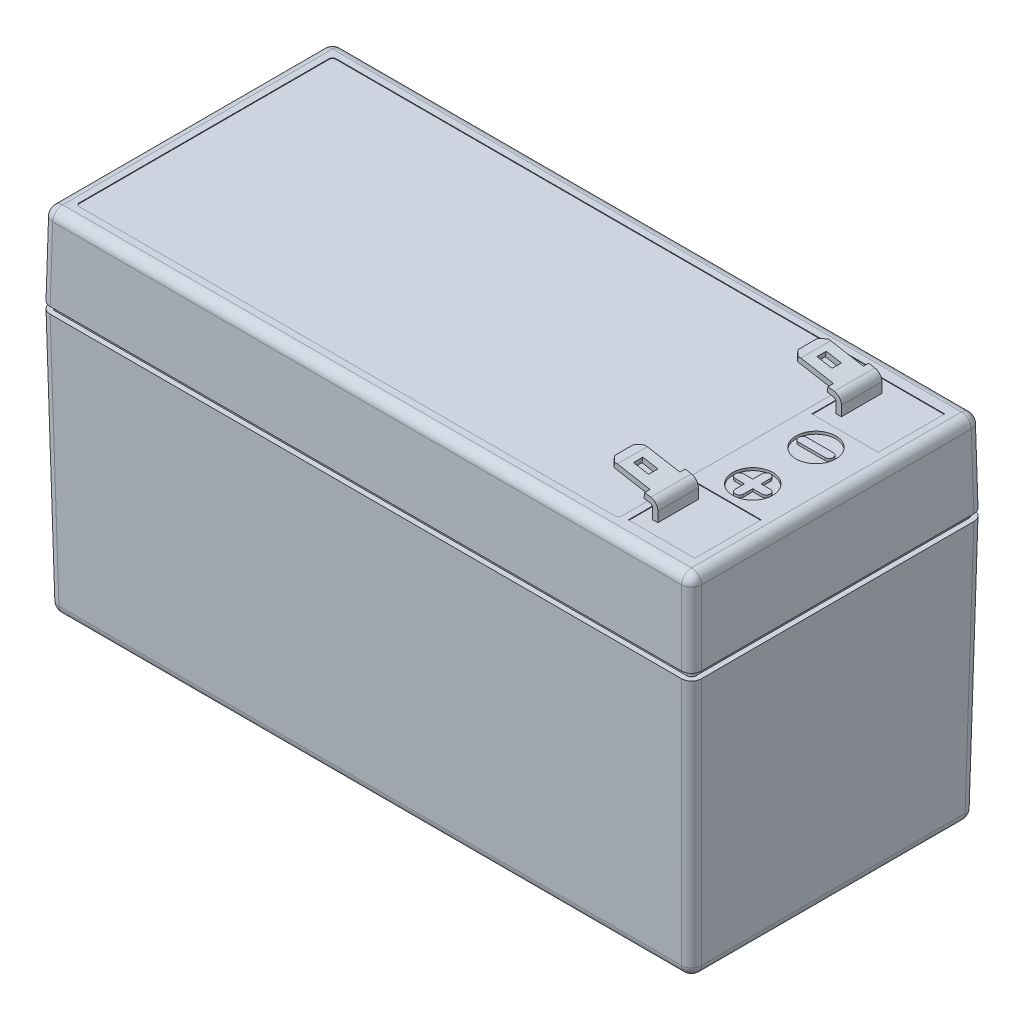
from build123d import *

# Parameters (mm, degrees)
SKETCH1_W                = 98
SKETCH1_H                = 44
EXTRUDE1_DEPTH           = 13
EXTRUDE1_TAPER           = 1
EXTRUDE1_OTHER_WAY_DEPTH = 40
EXTRUDE1_OTHER_WAY_TAPER = 1
FILLET1_R                = 1.5
SKETCH3_W                = 1.297153583
SKETCH3_H                = 1
EXTRUDE3_DEPTH           = 0.3
SKETCH4_3_W              = 3.5
SKETCH4_3_H              = 3.5
CUT_EXTRUDE1_DEPTH       = 0.5
SKETCH5_W                = 81.598076522
SKETCH5_H                = 38.598076522
CUT_EXTRUDE2_DEPTH       = 0.1
FILLET2_R                = 0.5
SKETCH6_W                = 10
SKETCH6_H                = 10
CUT_EXTRUDE3_DEPTH       = 0.1
EXTRUDE_THIN1_START      = 10.75
EXTRUDE_THIN1_DEPTH      = 6.1
SKETCH8_W                = 6.18946588
SKETCH8_H                = 0.8
SKETCH8_W_2              = 6.172101062
SKETCH8_W_3              = 2.3
SKETCH8_H_2              = 1.4
CUT_EXTRUDE4_DEPTH       = 0.8
FILLET3_R                = 0.5
FILLET4_R                = 1.3
CHAMFER1_SIZE            = 1.2
CHAMFER1_SIZE2           = 0.104986396
CHAMFER1_PART_2_SIZE     = 1.2
CHAMFER1_PART_2_SIZE2    = 0.104986396
CHAMFER1_PART_3_SIZE     = 1.2
CHAMFER1_PART_3_SIZE2    = 0.104986396
CHAMFER1_PART_4_SIZE     = 1.2
CHAMFER1_PART_4_SIZE2    = 0.104986396
CHAMFER2_SIZE            = 0.8
SKETCH9_R                = 3
CUT_EXTRUDE5_DEPTH       = 0.4


with BuildPart() as part:
    # Sketch1 → Extrude1 (new body)
    with BuildSketch(Plane(origin=(0, 0, 0), x_dir=(1, 0, 0), z_dir=(0, 1, 0))):
        Rectangle(SKETCH1_W, SKETCH1_H)
    extrude(amount=EXTRUDE1_DEPTH, taper=EXTRUDE1_TAPER)

    # Sketch1 → Extrude1 other way (add)
    with BuildSketch(Plane(origin=(0, 0, 0), x_dir=(1, 0, 0), z_dir=(0, 1, 0))):
        Rectangle(SKETCH1_W, SKETCH1_H)
    extrude(amount=-EXTRUDE1_OTHER_WAY_DEPTH, taper=EXTRUDE1_OTHER_WAY_TAPER)

    # Fillet1
    fillet1_edges = [part.edges().sort_by_distance(p)[0] for p in [
        (48.773084156, 13, 0),
        (-48.301797403, -40, 0),
        (-48.650898701, -20, 21.650898701),
        (0, -40, -21.301797403),
        (0, 13, -21.773084156),
        (-48.650898701, -20, -21.650898701),
        (48.301797403, -40, 0),
        (48.650898701, -20, -21.650898701),
        (0, -40, 21.301797403),
        (48.650898701, -20, 21.650898701),
        (-48.773084156, 13, 0),
        (0, 13, 21.773084156),
        (-48.886542078, 6.5, -21.886542078),
        (48.886542078, 6.5, -21.886542078),
        (48.886542078, 6.5, 21.886542078),
        (-48.886542078, 6.5, 21.886542078),
    ]]
    fillet(fillet1_edges, radius=FILLET1_R)

    # Cut-Sweep1: sweep along a curve in space
    with BuildLine() as cut_sweep1_path:
        Line((-49, 0, -20.500228457), (-49, 0, 20.500228457))
        add(Edge.make_bspline(
            [(-49, 0, 20.500228457), (-49, 0, 21.378829698), (-48.378829698, 0, 22), (-47.500228457, 0, 22)],
            knots=[0, 0, 0, 0, 1, 1, 1, 1], degree=3, weights=[1, 0.80480964, 0.80480964, 1]))
        Line((-47.500228457, 0, 22), (47.500228457, 0, 22))
        add(Edge.make_bspline(
            [(47.500228457, 0, 22), (48.378829698, 0, 22), (49, 0, 21.378829698), (49, 0, 20.500228457)],
            knots=[0, 0, 0, 0, 1, 1, 1, 1], degree=3, weights=[1, 0.80480964, 0.80480964, 1]))
        Line((49, 0, 20.500228457), (49, 0, -20.500228457))
        add(Edge.make_bspline(
            [(49, 0, -20.500228457), (49, 0, -21.378829698), (48.378829698, 0, -22), (47.500228457, 0, -22)],
            knots=[0, 0, 0, 0, 1, 1, 1, 1], degree=3, weights=[1, 0.80480964, 0.80480964, 1]))
        Line((47.500228457, 0, -22), (-47.500228457, 0, -22))
        add(Edge.make_bspline(
            [(-47.500228457, 0, -22), (-48.378829698, 0, -22), (-49, 0, -21.378829698), (-49, 0, -20.500228457)],
            knots=[0, 0, 0, 0, 1, 1, 1, 1], degree=3, weights=[1, 0.80480964, 0.80480964, 1]))
    # Sketch3 → Cut-Sweep1 (sweep, cut)
    with BuildSketch(Plane(origin=(0, 0, 0), x_dir=(0, 0, -1), z_dir=(1, 0, 0))):
        with Locations((21.848576792, 0)):
            Rectangle(SKETCH3_W, SKETCH3_H)
    sweep(path=cut_sweep1_path.line, mode=Mode.SUBTRACT)

    # Sketch4 → Extrude3 (add)
    with BuildSketch(Plane.XZ.offset(40)):
        Polygon((-44.627751508, -17.627751508), (-38.627751508, -17.627751508), (-38.627751508, -15.627751508), (-42.627751508, -15.627751508), (-42.627751508, -11.627751508), (-44.627751508, -11.627751508), align=None)
        Polygon((-44.627751508, 11.627751508), (-42.627751508, 11.627751508), (-42.627751508, 15.627751508), (-38.627751508, 15.627751508), (-38.627751508, 17.627751508), (-44.627751508, 17.627751508), align=None)
        Polygon((44.627751508, -11.627751508), (42.627751508, -11.627751508), (42.627751508, -15.627751508), (38.627751508, -15.627751508), (38.627751508, -17.627751508), (44.627751508, -17.627751508), align=None)
        Polygon((44.627751508, 17.627751508), (38.627751508, 17.627751508), (38.627751508, 15.627751508), (42.627751508, 15.627751508), (42.627751508, 11.627751508), (44.627751508, 11.627751508), align=None)
    extrude(amount=EXTRUDE3_DEPTH)

    # Sketch4_3 → Cut-Extrude1 (cut)
    with BuildSketch(Plane.XZ.offset(40)):
        with Locations((-16.75, 0)):
            Rectangle(SKETCH4_3_W, SKETCH4_3_H)
        with Locations((16.75, 0)):
            Rectangle(SKETCH4_3_W, SKETCH4_3_H)
    extrude(amount=-CUT_EXTRUDE1_DEPTH, mode=Mode.SUBTRACT)

    # Sketch5 → Cut-Extrude2 (cut)
    with BuildSketch(Plane(origin=(0, 13, 0), x_dir=(-1, 0, 0), z_dir=(0, 1, 0))):
        with Locations((5.5, 0)):
            Rectangle(SKETCH5_W, SKETCH5_H)
    extrude(amount=-CUT_EXTRUDE2_DEPTH, mode=Mode.SUBTRACT)

    # Fillet2
    fillet2_edges = [part.edges().sort_by_distance(p)[0] for p in [
        (-46.299038261, 12.95, 19.299038261),
        (-46.299038261, 12.95, -19.299038261),
        (35.299038261, 12.95, -19.299038261),
        (35.299038261, 12.95, 19.299038261),
    ]]
    fillet(fillet2_edges, radius=FILLET2_R)

    # Sketch6 → Cut-Extrude3 (cut)
    with BuildSketch(Plane(origin=(0, 13, 0), x_dir=(-1, 0, 0), z_dir=(0, 1, 0))):
        with Locations((-41.299038261, 13.799038261)):
            Rectangle(SKETCH6_W, SKETCH6_H)
        with Locations((-41.299038261, -13.799038261)):
            Rectangle(SKETCH6_W, SKETCH6_H)
    extrude(amount=-CUT_EXTRUDE3_DEPTH, mode=Mode.SUBTRACT)

    # Sketch7 → Extrude-Thin1 (add)
    with BuildSketch(Plane.XY.offset(EXTRUDE_THIN1_START)):
        Polygon((38.799038261, 11.52617861), (38.799038261, 15.5), (30.723614687, 16.923915057), (30.584696144, 16.136068854), (37.999038261, 14.828720295), (37.999038261, 11.52617861), align=None)
    extrude_thin1 = extrude(amount=EXTRUDE_THIN1_DEPTH)

    # Sketch8 → Cut-Extrude4 (cut)
    with BuildSketch(Plane(origin=(3.820590268, 21.667644125, 0), x_dir=(-0.984807753, 0.173648178, 0), z_dir=(0.173648178, 0.984807753, 0))):
        with Locations((-30.412779875, 16.45)):
            Rectangle(SKETCH8_W, SKETCH8_H)
        with Locations((-30.404097466, 11.15)):
            Rectangle(SKETCH8_W_2, SKETCH8_H)
        with Locations((-30.55624518, 13.8)):
            Rectangle(SKETCH8_W_3, SKETCH8_H_2)
    cut_extrude4 = extrude(amount=-CUT_EXTRUDE4_DEPTH, mode=Mode.SUBTRACT)

    # Mirror1: Extrude-Thin1, Cut-Extrude4 across plane
    add(extrude_thin1.mirror(Plane.XY))
    add(cut_extrude4.mirror(Plane.XY), mode=Mode.SUBTRACT)

    # Fillet3
    fillet3_edges = [part.edges().sort_by_distance(p)[0] for p in [
        (37.999038261, 14.828720295, 13.8),
        (37.999038261, 14.828720295, -13.8),
    ]]
    fillet(fillet3_edges, radius=FILLET3_R)

    # Fillet4
    fillet4_edges = [part.edges().sort_by_distance(p)[0] for p in [
        (38.799038261, 15.5, 13.8),
        (38.799038261, 15.5, -13.8),
    ]]
    fillet(fillet4_edges, radius=FILLET4_R)

    # Chamfer1
    chamfer1_edges = [part.edges().sort_by_distance(p)[0] for p in [
        (30.584696144, 16.136068854, 13.8),
    ]]
    chamfer1_side = [part.faces().sort_by_distance(p)[0] for p in [
        (37.124445736, 14.982934554, 10.843675133),
    ]]
    chamfer(chamfer1_edges, length=CHAMFER1_SIZE, length2=CHAMFER1_SIZE2, reference=chamfer1_side[0])

    # Chamfer1 part 2
    chamfer1_part_2_edges = [part.edges().sort_by_distance(p)[0] for p in [
        (30.723614687, 16.923915057, 13.8),
    ]]
    chamfer1_part_2_side = [part.faces().sort_by_distance(p)[0] for p in [
        (37.263364278, 15.770780757, 10.843675133),
    ]]
    chamfer(chamfer1_part_2_edges, length=CHAMFER1_PART_2_SIZE, length2=CHAMFER1_PART_2_SIZE2, reference=chamfer1_part_2_side[0])

    # Chamfer1 part 3
    chamfer1_part_3_edges = [part.edges().sort_by_distance(p)[0] for p in [
        (30.723614687, 16.923915057, -13.8),
    ]]
    chamfer1_part_3_side = [part.faces().sort_by_distance(p)[0] for p in [
        (37.263364278, 15.770780757, -10.843675133),
    ]]
    chamfer(chamfer1_part_3_edges, length=CHAMFER1_PART_3_SIZE, length2=CHAMFER1_PART_3_SIZE2, reference=chamfer1_part_3_side[0])

    # Chamfer1 part 4
    chamfer1_part_4_edges = [part.edges().sort_by_distance(p)[0] for p in [
        (30.584696144, 16.136068854, -13.8),
    ]]
    chamfer1_part_4_side = [part.faces().sort_by_distance(p)[0] for p in [
        (37.124445736, 14.982934554, -10.843675133),
    ]]
    chamfer(chamfer1_part_4_edges, length=CHAMFER1_PART_4_SIZE, length2=CHAMFER1_PART_4_SIZE2, reference=chamfer1_part_4_side[0])

    # Chamfer2
    chamfer2_edges = [part.edges().sort_by_distance(p)[0] for p in [
        (30.654155415, 16.529991956, -11.55),
        (30.654155415, 16.529991956, -16.05),
        (30.654155415, 16.529991956, 11.55),
        (30.654155415, 16.529991956, 16.05),
    ]]
    chamfer(chamfer2_edges, length=CHAMFER2_SIZE)

    # Sketch9 → Cut-Extrude5 (cut)
    with BuildSketch(Plane(origin=(0, 13, 0), x_dir=(-1, 0, 0), z_dir=(0, 1, 0))):
        with Locations((-40.96939399, -4.75)):
            Circle(SKETCH9_R)
        with BuildLine():
            ThreePointArc((-42.96939399, -5.375), (-43.59439399, -4.75), (-42.96939399, -4.125))
            Line((-42.96939399, -4.125), (-38.96939399, -4.125))
            ThreePointArc((-38.96939399, -4.125), (-38.34439399, -4.75), (-38.96939399, -5.375))
            Line((-38.96939399, -5.375), (-42.96939399, -5.375))
        make_face(mode=Mode.SUBTRACT)
        with Locations((-40.96939399, 4.75)):
            Circle(SKETCH9_R)
        with BuildLine():
            Line((-41.59439399, 5.375), (-41.59439399, 6.75))
            ThreePointArc((-41.59439399, 6.75), (-40.96939399, 7.375), (-40.34439399, 6.75))
            Line((-40.34439399, 6.75), (-40.34439399, 5.375))
            Line((-40.34439399, 5.375), (-38.96939399, 5.375))
            ThreePointArc((-38.96939399, 5.375), (-38.34439399, 4.75), (-38.96939399, 4.125))
            Line((-38.96939399, 4.125), (-40.34439399, 4.125))
            Line((-40.34439399, 4.125), (-40.34439399, 2.75))
            ThreePointArc((-40.34439399, 2.75), (-40.96939399, 2.125), (-41.59439399, 2.75))
            Line((-41.59439399, 2.75), (-41.59439399, 4.125))
            Line((-41.59439399, 4.125), (-42.96939399, 4.125))
            ThreePointArc((-42.96939399, 4.125), (-43.59439399, 4.75), (-42.96939399, 5.375))
            Line((-42.96939399, 5.375), (-41.59439399, 5.375))
        make_face(mode=Mode.SUBTRACT)
    extrude(amount=-CUT_EXTRUDE5_DEPTH, mode=Mode.SUBTRACT)


solid = part.part
